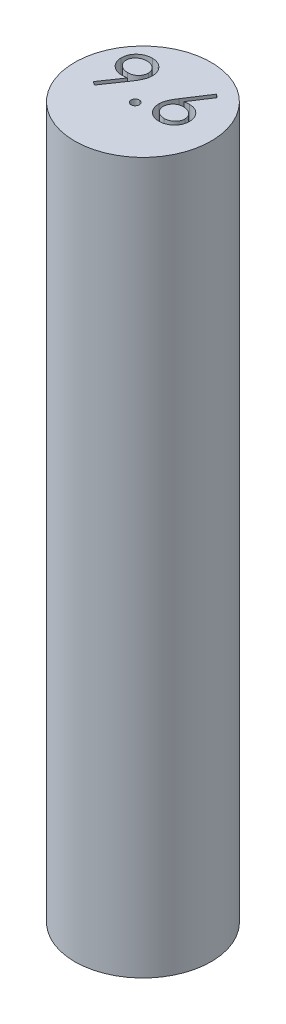
from build123d import *

# Parameters (mm, degrees)
SKETCH1_R           = 4.8
BOSS_EXTRUDE1_DEPTH = 50
CUT_EXTRUDE1_DEPTH  = 3


with BuildPart() as part:
    # Sketch1 → Boss-Extrude1 (new body)
    with BuildSketch(Plane(origin=(0, 0, 0), x_dir=(1, 0, 0), z_dir=(0, 1, 0))):
        Circle(SKETCH1_R)
    extrude(amount=BOSS_EXTRUDE1_DEPTH)

    # Sketch2 → Cut-Extrude1 (cut)
    with BuildSketch(Plane(origin=(0, 50, 0), x_dir=(1, 0, 0), z_dir=(0, 1, 0))):
        with BuildLine():
            Line((2.124504817, 3.046153232), (2.366391836, 2.856149226))
            Line((2.366391836, 2.856149226), (1.441612188, 1.441986565))
            add(Edge.make_bspline(
                [(1.441612188, 1.441986565), (1.503182465, 1.451800426), (1.623282252, 1.470943471), (1.744848151, 1.474101416), (1.804092156, 1.475640411)],
                knots=[0, 0, 0, 0, 0.000186809, 0.000364392, 0.000364392, 0.000364392, 0.000364392], degree=3))
            add(Edge.make_bspline(
                [(1.804092156, 1.475640411), (1.839664653, 1.4746843), (1.909688053, 1.472802222), (2.012494855, 1.458318372), (2.111283791, 1.43549326), (2.205645403, 1.402221004), (2.295918385, 1.359718649), (2.382620781, 1.308779779), (2.464122792, 1.246774099), (2.541473971, 1.177509143), (2.611701068, 1.100792159), (2.673877124, 1.019390822), (2.726103915, 0.933389941), (2.768477837, 0.842833075), (2.801382716, 0.747859815), (2.825370361, 0.648591676), (2.839549954, 0.544960204), (2.841475444, 0.474482029), (2.842453535, 0.438681277)],
                knots=[0, 0, 0, 0, 0.000106683, 0.000210003, 0.00031085, 0.000410412, 0.000509526, 0.000609808, 0.000711471, 0.00081622, 0.000920922, 0.001023007, 0.001123049, 0.001222163, 0.001322387, 0.001424078, 0.001528093, 0.001635477, 0.001635477, 0.001635477, 0.001635477], degree=3))
            add(Edge.make_bspline(
                [(2.842453535, 0.438681277), (2.84103043, 0.389701573), (2.838230096, 0.293321107), (2.8103263, 0.152944401), (2.766966655, 0.019211885), (2.704989127, -0.105741286), (2.628006744, -0.221743856), (2.534129151, -0.324529321), (2.426685663, -0.416199359), (2.305198865, -0.492855978), (2.174455901, -0.555459029), (2.037103903, -0.600424271), (1.894476757, -0.62810774), (1.797672149, -0.631578343), (1.748703535, -0.633333948)],
                knots=[0, 0, 0, 0, 0.000146776, 0.00028882, 0.000427614, 0.000567461, 0.000705914, 0.000843912, 0.000983689, 0.001128394, 0.001273595, 0.001417489, 0.001560911, 0.001707729, 0.001707729, 0.001707729, 0.001707729], degree=3))
            add(Edge.make_bspline(
                [(1.748703535, -0.633333948), (1.701606834, -0.631805742), (1.608316516, -0.628778634), (1.471083722, -0.601812696), (1.339220704, -0.558105593), (1.213651323, -0.497891315), (1.09733071, -0.421833432), (0.993265074, -0.330271152), (0.901973299, -0.225161687), (0.825998679, -0.10652134), (0.765739947, 0.020968617), (0.720550021, 0.153905774), (0.694153778, 0.291805755), (0.690465221, 0.385286895), (0.688607381, 0.432371181)],
                knots=[0, 0, 0, 0, 0.000141176, 0.000279646, 0.000417774, 0.000557008, 0.000696242, 0.000833365, 0.000971544, 0.001112541, 0.001254608, 0.001393623, 0.001532781, 0.001674001, 0.001674001, 0.001674001, 0.001674001], degree=3))
            add(Edge.make_bspline(
                [(0.688607381, 0.432371181), (0.689788826, 0.468415764), (0.692201111, 0.542011916), (0.709044501, 0.653475944), (0.736109296, 0.767527026), (0.766419542, 0.864281219), (0.798445152, 0.943542741), (0.825097692, 1.007446232), (0.858271688, 1.073207305), (0.893645069, 1.143080941), (0.934401938, 1.215266374), (0.978717587, 1.290970043), (1.027817238, 1.368987971), (1.062237401, 1.421932166), (1.079833342, 1.448997783)],
                knots=[0, 0, 0, 0, 0.000108118, 0.000220757, 0.000337422, 0.000459596, 0.000524434, 0.000593848, 0.000667222, 0.000745302, 0.000828791, 0.000915849, 0.00100845, 0.001105299, 0.001105299, 0.001105299, 0.001105299], degree=3))
            Line((1.079833342, 1.448997783), (2.124504817, 3.046153232))
        make_face()
        with BuildLine():
            add(Edge.make_bspline(
                [(1.738186708, 1.116666052), (1.711524463, 1.115888009), (1.659445353, 1.114368263), (1.583037939, 1.105543012), (1.510724687, 1.088923946), (1.441547554, 1.067757614), (1.376799851, 1.038654554), (1.316011011, 1.003302755), (1.258945959, 0.961681577), (1.206202407, 0.914380666), (1.158382744, 0.862592633), (1.117201613, 0.807123111), (1.081679213, 0.749308908), (1.052797394, 0.688666966), (1.030307318, 0.625220466), (1.014039067, 0.559261217), (1.004985316, 0.490346911), (1.003479085, 0.443614408), (1.002709945, 0.419750988)],
                knots=[0, 0, 0, 0, 8.0005e-05, 0.000156272, 0.000230267, 0.000302332, 0.000372951, 0.000442698, 0.000512957, 0.000584457, 0.000654919, 0.00072405, 0.000791387, 0.000858185, 0.000925156, 0.000993006, 0.001061623, 0.001133223, 0.001133223, 0.001133223, 0.001133223], degree=3))
            add(Edge.make_bspline(
                [(1.002709945, 0.419750988), (1.003336306, 0.396101009), (1.004564508, 0.349726919), (1.015716828, 0.281387739), (1.03275191, 0.215622831), (1.058092306, 0.152771232), (1.088319194, 0.091874914), (1.128224518, 0.035139629), (1.172441304, -0.020880442), (1.225295238, -0.071881913), (1.282018601, -0.119338537), (1.342619803, -0.160818791), (1.405779763, -0.196304964), (1.472351185, -0.224116062), (1.541389569, -0.246940349), (1.613470123, -0.263001828), (1.688642979, -0.272082354), (1.739564917, -0.273590547), (1.765530458, -0.274359589)],
                knots=[0, 0, 0, 0, 7.09e-05, 0.000139024, 0.000207221, 0.000274272, 0.000342002, 0.000410648, 0.000481932, 0.000555803, 0.000630491, 0.000703613, 0.000775798, 0.000847422, 0.000919703, 0.000993697, 0.001068572, 0.001146476, 0.001146476, 0.001146476, 0.001146476], degree=3))
            add(Edge.make_bspline(
                [(1.765530458, -0.274359589), (1.791495956, -0.273590487), (1.842417811, -0.272082175), (1.917591271, -0.263002506), (1.98966959, -0.246937859), (2.058716098, -0.224125088), (2.125257529, -0.196271479), (2.188362251, -0.161039559), (2.248390344, -0.119083441), (2.305150944, -0.071963013), (2.357784882, -0.020590161), (2.403062161, 0.034639561), (2.441745394, 0.092333457), (2.473179581, 0.152531347), (2.498240873, 0.215660834), (2.51536234, 0.281377558), (2.526491629, 0.349729584), (2.527722995, 0.396101909), (2.52835097, 0.419750988)],
                knots=[0, 0, 0, 0, 7.7903e-05, 0.000152779, 0.000226773, 0.000299053, 0.000370678, 0.000442863, 0.000515408, 0.000590096, 0.000663967, 0.000735694, 0.000803948, 0.000872001, 0.000939052, 0.001007249, 0.001075373, 0.001146273, 0.001146273, 0.001146273, 0.001146273], degree=3))
            add(Edge.make_bspline(
                [(2.52835097, 0.419750988), (2.527800677, 0.443645539), (2.526720631, 0.490542772), (2.514504683, 0.55923039), (2.497562309, 0.625555596), (2.471979278, 0.689101545), (2.438742733, 0.749617473), (2.398259326, 0.807409073), (2.351426756, 0.862919421), (2.297329216, 0.914482229), (2.238438982, 0.961629307), (2.175823397, 1.003248863), (2.110315423, 1.03837384), (2.041981481, 1.067680942), (1.970038598, 1.088830417), (1.895648259, 1.10548366), (1.817859016, 1.114345677), (1.765082408, 1.115882743), (1.738186708, 1.116666052)],
                knots=[0, 0, 0, 0, 7.16e-05, 0.000140528, 0.000208725, 0.000276686, 0.0003454, 0.000415417, 0.000488044, 0.000562919, 0.000639239, 0.000714104, 0.000788135, 0.00086197, 0.000936714, 0.001012762, 0.001090422, 0.001171127, 0.001171127, 0.001171127, 0.001171127], degree=3))
        make_face(mode=Mode.SUBTRACT)
        with BuildLine():
            add(Edge.make_bspline(
                [(-0.231099206, -0.025863749), (-0.211608994, -0.027021916), (-0.173400712, -0.029292366), (-0.118161583, -0.04486904), (-0.068166924, -0.0725277), (-0.023634679, -0.109390479), (0.013071798, -0.154086142), (0.04171615, -0.203682051), (0.057157135, -0.259383643), (0.059411047, -0.297813318), (0.060567461, -0.317530416)],
                knots=[0, 0, 0, 0, 5.8463e-05, 0.000114609, 0.000170453, 0.000228714, 0.000286975, 0.000343156, 0.000399303, 0.000458464, 0.000458464, 0.000458464, 0.000458464], degree=3))
            add(Edge.make_bspline(
                [(0.060567461, -0.317530416), (0.05937186, -0.336773746), (0.057014153, -0.374721309), (0.041751545, -0.430002772), (0.012853494, -0.479629676), (-0.023381499, -0.524931814), (-0.068177932, -0.561872685), (-0.118279779, -0.58929603), (-0.173271037, -0.60598801), (-0.21158736, -0.608114307), (-0.231099206, -0.609197082)],
                knots=[0, 0, 0, 0, 5.7765e-05, 0.000113912, 0.000170093, 0.000228896, 0.000287156, 0.000343, 0.000399343, 0.000457806, 0.000457806, 0.000457806, 0.000457806], degree=3))
            add(Edge.make_bspline(
                [(-0.231099206, -0.609197082), (-0.250625112, -0.608153485), (-0.288744794, -0.60611611), (-0.343530789, -0.588953304), (-0.393937757, -0.562129844), (-0.438725469, -0.524862934), (-0.475263941, -0.479862791), (-0.502889323, -0.429660994), (-0.519479472, -0.374879557), (-0.521661345, -0.336804914), (-0.522765873, -0.317530416)],
                knots=[0, 0, 0, 0, 5.8463e-05, 0.000114135, 0.000170596, 0.000228856, 0.000287659, 0.000343502, 0.000399846, 0.000457611, 0.000457611, 0.000457611, 0.000457611], degree=3))
            add(Edge.make_bspline(
                [(-0.522765873, -0.317530416), (-0.521703774, -0.297781036), (-0.519630155, -0.259222796), (-0.502854495, -0.204023689), (-0.475478283, -0.153855249), (-0.438472888, -0.109458669), (-0.393948592, -0.072271367), (-0.343652387, -0.045206573), (-0.288612847, -0.029166161), (-0.250602908, -0.026983645), (-0.231099206, -0.025863749)],
                knots=[0, 0, 0, 0, 5.9161e-05, 0.000115504, 0.000171348, 0.000229609, 0.000287869, 0.00034433, 0.000399803, 0.000458266, 0.000458266, 0.000458266, 0.000458266], degree=3))
        make_face()
        with BuildLine():
            Line((-2.721142012, -0.696968732), (-2.972143614, -0.522389405))
            Line((-2.972143614, -0.522389405), (-1.998986563, 0.900186717))
            add(Edge.make_bspline(
                [(-1.998986563, 0.900186717), (-2.061077299, 0.892593653), (-2.183337419, 0.877642488), (-2.306474521, 0.874895834), (-2.367075505, 0.873544089)],
                knots=[0, 0, 0, 0, 0.000187529, 0.000369255, 0.000369255, 0.000369255, 0.000369255], degree=3))
            add(Edge.make_bspline(
                [(-2.367075505, 0.873544089), (-2.403817553, 0.874485165), (-2.47593898, 0.876332416), (-2.581970632, 0.890974224), (-2.683856193, 0.913524352), (-2.781325549, 0.947173107), (-2.874745054, 0.988991316), (-2.963910767, 1.04084833), (-3.048702658, 1.101854621), (-3.128210068, 1.171687613), (-3.200521807, 1.248365665), (-3.264945104, 1.329521308), (-3.318486236, 1.416097279), (-3.362962822, 1.506327498), (-3.396693275, 1.601508849), (-3.421255813, 1.700558249), (-3.436378167, 1.804169891), (-3.438177263, 1.874695022), (-3.43909073, 1.910503223)],
                knots=[0, 0, 0, 0, 0.000110185, 0.000216284, 0.000320547, 0.000422759, 0.000525058, 0.000627155, 0.000731643, 0.000837964, 0.0009441, 0.00104747, 0.001148247, 0.001248901, 0.001348697, 0.001450555, 0.001554666, 0.00166205, 0.00166205, 0.00166205, 0.00166205], degree=3))
            add(Edge.make_bspline(
                [(-3.43909073, 1.910503223), (-3.437356295, 1.959471876), (-3.433951951, 2.055587407), (-3.406553434, 2.196021176), (-3.361493095, 2.32880772), (-3.298664718, 2.453597914), (-3.219529997, 2.568596653), (-3.124421406, 2.672205262), (-3.013917442, 2.762950116), (-2.890535423, 2.840954194), (-2.757182402, 2.903689191), (-2.617513744, 2.949928491), (-2.472599624, 2.977127239), (-2.374431954, 2.9807131), (-2.325008198, 2.982518448)],
                knots=[0, 0, 0, 0, 0.000146818, 0.000288173, 0.000427413, 0.000566316, 0.000705952, 0.000844895, 0.000986821, 0.001133677, 0.001281714, 0.001427825, 0.001574003, 0.00172222, 0.00172222, 0.00172222, 0.00172222], degree=3))
            add(Edge.make_bspline(
                [(-2.325008198, 2.982518448), (-2.276519778, 2.980688284), (-2.180711231, 2.977072055), (-2.039822225, 2.950588086), (-1.904881208, 2.905951413), (-1.776636221, 2.844266849), (-1.657896809, 2.766945941), (-1.551120998, 2.674811418), (-1.458745458, 2.56780589), (-1.380921578, 2.4485174), (-1.318451537, 2.320350419), (-1.273379254, 2.186566497), (-1.245633615, 2.048127775), (-1.242137288, 1.954333301), (-1.240372781, 1.906997614)],
                knots=[0, 0, 0, 0, 0.000145418, 0.000287333, 0.000428343, 0.000570713, 0.000713061, 0.00085223, 0.000992387, 0.001135706, 0.001278381, 0.001418948, 0.001558239, 0.001700158, 0.001700158, 0.001700158, 0.001700158], degree=3))
            add(Edge.make_bspline(
                [(-1.240372781, 1.906997614), (-1.24155119, 1.870253847), (-1.243941298, 1.795728306), (-1.260677605, 1.682497964), (-1.28909779, 1.567046734), (-1.321349489, 1.469325138), (-1.352481656, 1.388616689), (-1.381782788, 1.324865109), (-1.414294942, 1.257763845), (-1.452213707, 1.188016507), (-1.492976004, 1.114733972), (-1.53903528, 1.038651257), (-1.589340852, 0.959666263), (-1.625170572, 0.906419175), (-1.643517813, 0.879153063)],
                knots=[0, 0, 0, 0, 0.000110219, 0.000223552, 0.000342587, 0.000466527, 0.000532018, 0.000601997, 0.000676938, 0.00075567, 0.000840114, 0.000928491, 0.001022434, 0.001121023, 0.001121023, 0.001121023, 0.001121023], degree=3))
            Line((-1.643517813, 0.879153063), (-2.721142012, -0.696968732))
        make_face()
        with BuildLine():
            add(Edge.make_bspline(
                [(-2.308882396, 1.232518448), (-2.281048382, 1.233278831), (-2.226865019, 1.23475904), (-2.14748772, 1.243768282), (-2.072563517, 1.259742268), (-2.001892267, 1.28266198), (-1.934765365, 1.310318649), (-1.872249037, 1.345530635), (-1.814290962, 1.38754727), (-1.760503035, 1.434757286), (-1.712739035, 1.487207869), (-1.670196005, 1.542104976), (-1.634035437, 1.599689586), (-1.60547216, 1.660682848), (-1.581987585, 1.723600057), (-1.565769573, 1.789454412), (-1.556785239, 1.857902812), (-1.555253664, 1.90440147), (-1.554475345, 1.928031268)],
                knots=[0, 0, 0, 0, 8.3507e-05, 0.00016256, 0.000239294, 0.000312908, 0.000385178, 0.000456751, 0.000527578, 0.000599603, 0.000671055, 0.000740051, 0.000807755, 0.000874553, 0.000941763, 0.001008931, 0.001077548, 0.001148448, 0.001148448, 0.001148448, 0.001148448], degree=3))
            add(Edge.make_bspline(
                [(-1.554475345, 1.928031268), (-1.555145014, 1.951670933), (-1.556464679, 1.998255793), (-1.567051979, 2.066805533), (-1.585677202, 2.132498794), (-1.610667687, 2.195695224), (-1.643587925, 2.255875596), (-1.683091411, 2.313795468), (-1.73002386, 2.369087595), (-1.784026427, 2.420451579), (-1.84226098, 2.467799478), (-1.90432148, 2.509585554), (-1.969696396, 2.54460675), (-2.037986886, 2.57350572), (-2.109335235, 2.596057496), (-2.183699223, 2.612274861), (-2.261454628, 2.621246615), (-2.314235914, 2.62276851), (-2.341133999, 2.623544089)],
                knots=[0, 0, 0, 0, 7.09e-05, 0.000139717, 0.000207422, 0.000275384, 0.000343146, 0.000412766, 0.000485392, 0.000560268, 0.000636041, 0.000710323, 0.000784354, 0.000858188, 0.000932471, 0.001008519, 0.001086179, 0.001166885, 0.001166885, 0.001166885, 0.001166885], degree=3))
            add(Edge.make_bspline(
                [(-2.341133999, 2.623544089), (-2.367798152, 2.622767257), (-2.420113002, 2.621243119), (-2.497177161, 2.612291914), (-2.571038329, 2.59594843), (-2.642179949, 2.573516166), (-2.71046841, 2.544604595), (-2.775840242, 2.509583719), (-2.837915259, 2.467809097), (-2.89609398, 2.420414324), (-2.950191902, 2.369326678), (-2.996317431, 2.313553249), (-3.035911323, 2.255905725), (-3.068786326, 2.195687217), (-3.093788843, 2.132500931), (-3.112410845, 2.066804954), (-3.12299901, 1.998255944), (-3.124318557, 1.951670984), (-3.124988166, 1.928031268)],
                knots=[0, 0, 0, 0, 8.0005e-05, 0.000156969, 0.000232332, 0.000306614, 0.000380449, 0.000454479, 0.000528762, 0.000604535, 0.000679411, 0.000751586, 0.000821205, 0.000888968, 0.00095693, 0.001024634, 0.001093451, 0.001164351, 0.001164351, 0.001164351, 0.001164351], degree=3))
            add(Edge.make_bspline(
                [(-3.124988166, 1.928031268), (-3.124382239, 1.904383069), (-3.123187242, 1.857744493), (-3.111659453, 1.7892181), (-3.092381173, 1.723529906), (-3.066561782, 1.660041199), (-3.032560192, 1.599369341), (-2.990836344, 1.541801979), (-2.941930798, 1.486686529), (-2.88649731, 1.434879317), (-2.825829149, 1.387327142), (-2.761032403, 1.34579676), (-2.693222566, 1.310724315), (-2.622160936, 1.282582931), (-2.548374136, 1.259971268), (-2.471199004, 1.243797722), (-2.390890767, 1.234845456), (-2.336480785, 1.233301559), (-2.308882396, 1.232518448)],
                knots=[0, 0, 0, 0, 7.09e-05, 0.000139828, 0.000207725, 0.00027595, 0.000345002, 0.000415829, 0.000488844, 0.000565728, 0.000643147, 0.000719775, 0.000796287, 0.0008718, 0.000948761, 0.001027552, 0.001107998, 0.001190805, 0.001190805, 0.001190805, 0.001190805], degree=3))
        make_face(mode=Mode.SUBTRACT)
    extrude(amount=-CUT_EXTRUDE1_DEPTH, mode=Mode.SUBTRACT)


solid = part.part
